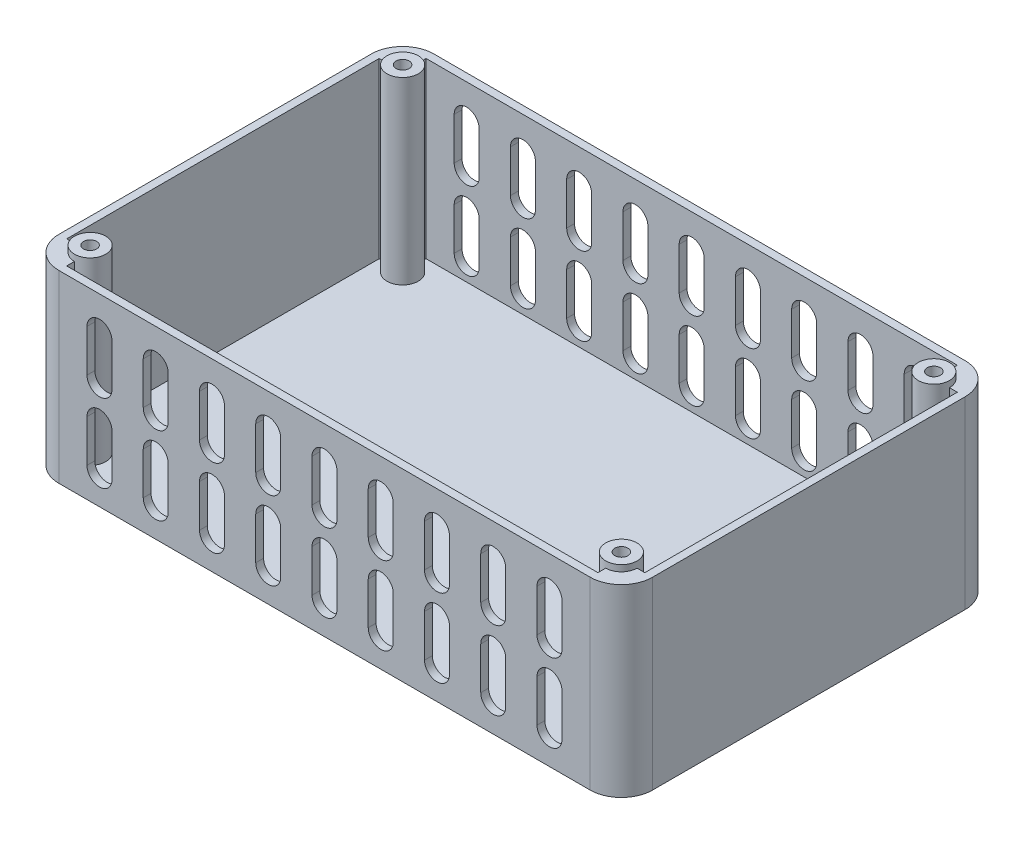
from build123d import *

# Parameters (mm, degrees)
SKETCH25_W                  = 190
SKETCH25_H                  = 120
BOSS_EXTRUDE5_DEPTH         = 55
FILLET2_R                   = 10
SHELL4_T                    = -2.5
SKETCH26_R                  = 5
BOSS_EXTRUDE8_DEPTH         = 57.5
TAP_DRILL_FOR_M5_TAP1_D     = 4.2
TAP_DRILL_FOR_M5_TAP1_DEPTH = 20
TAP_DRILL_FOR_M5_TAP1_TIP   = 1.2618073
BOSS_EXTRUDE10_DEPTH        = 1
CUT_EXTRUDE2_DEPTH          = 3
BOSS_EXTRUDE13_DEPTH        = 3
BOSS_EXTRUDE14_DEPTH        = 55.5
CUT_EXTRUDE3_DEPTH          = 3


with BuildPart() as part:
    # Sketch25 → Boss-Extrude5 (new body)
    with BuildSketch(Plane(origin=(0, 0, 0), x_dir=(1, 0, 0), z_dir=(0, 1, 0))):
        with Locations((-0.175936119, -144.891398577)):
            Rectangle(SKETCH25_W, SKETCH25_H)
    extrude(amount=BOSS_EXTRUDE5_DEPTH)

    # Fillet2
    fillet2_edges = [part.edges().sort_by_distance(p)[0] for p in [
        (-95.175936119, 27.5, 84.891398577),
        (94.824063881, 27.5, 84.891398577),
        (94.824063881, 27.5, 204.891398577),
        (-95.175936119, 27.5, 204.891398577),
    ]]
    fillet(fillet2_edges, radius=FILLET2_R)

    # Shell4
    shell4_openings = [part.faces().sort_by_distance(p)[0] for p in [
        (-0.175936119, 55, 144.891398577),
    ]]
    offset(amount=SHELL4_T, openings=shell4_openings, kind=Kind.INTERSECTION)

    # Sketch26 → Boss-Extrude8 (add)
    with BuildSketch(Plane(origin=(0, 2.5, 0), x_dir=(1, 0, 0), z_dir=(0, 1, 0))):
        with Locations((-85.175936119, -94.891398577)):
            Circle(SKETCH26_R)
        with Locations((84.824063881, -94.891398577)):
            Circle(SKETCH26_R)
        with Locations((-85.175936119, -194.891398577)):
            Circle(SKETCH26_R)
        with Locations((84.824063881, -194.891398577)):
            Circle(SKETCH26_R)
    extrude(amount=BOSS_EXTRUDE8_DEPTH)

    # Tap Drill for M5 Tap1
    with Locations(Plane(origin=(0, 60, 0), x_dir=(1, 0, 0), z_dir=(0, 1, 0))):
        with Locations((-85.175936119, -94.891398577), (-85.175936119, -194.891398577), (84.824063881, -94.891398577), (84.824063881, -194.891398577)):
            Hole(TAP_DRILL_FOR_M5_TAP1_D / 2, depth=TAP_DRILL_FOR_M5_TAP1_DEPTH)
            with Locations((0, 0, -(TAP_DRILL_FOR_M5_TAP1_DEPTH + TAP_DRILL_FOR_M5_TAP1_TIP / 2))):  # 118° drill point
                Cone(0, TAP_DRILL_FOR_M5_TAP1_D / 2, TAP_DRILL_FOR_M5_TAP1_TIP, mode=Mode.SUBTRACT)

    # Sketch37 → Boss-Extrude10 (add)
    with BuildSketch(Plane.XZ):
        with BuildLine():
            Line((94.824063881, 94.891398577), (94.824063881, 194.891398577))
            ThreePointArc((94.824063881, 194.891398577), (91.895131693, 201.962466389), (84.824063881, 204.891398577))
            Line((84.824063881, 204.891398577), (-85.175936119, 204.891398577))
            ThreePointArc((-85.175936119, 204.891398577), (-92.247003931, 201.962466389), (-95.175936119, 194.891398577))
            Line((-95.175936119, 194.891398577), (-95.175936119, 94.891398577))
            ThreePointArc((-95.175936119, 94.891398577), (-92.247003931, 87.820330766), (-85.175936119, 84.891398577))
            Line((-85.175936119, 84.891398577), (84.824063881, 84.891398577))
            ThreePointArc((84.824063881, 84.891398577), (91.895131693, 87.820330766), (94.824063881, 94.891398577))
        make_face()
    extrude(amount=BOSS_EXTRUDE10_DEPTH)

    # Sketch41 → Cut-Extrude2 (cut)
    with BuildSketch(Plane(origin=(0, 0, 84.891398577), x_dir=(-1, 0, 0), z_dir=(0, 0, -1))):
        with BuildLine():
            Line((-67.824063881, 47), (-67.824063881, 33.5))
            ThreePointArc((-67.824063881, 33.5), (-71.824063881, 29.5), (-75.824063881, 33.5))
            Line((-75.824063881, 33.5), (-75.824063881, 47))
            ThreePointArc((-75.824063881, 47), (-71.824063881, 51), (-67.824063881, 47))
        make_face()
        with BuildLine():
            Line((-49.824063881, 47), (-49.824063881, 33.5))
            ThreePointArc((-49.824063881, 33.5), (-53.824063881, 29.5), (-57.824063881, 33.5))
            Line((-57.824063881, 33.5), (-57.824063881, 47))
            ThreePointArc((-57.824063881, 47), (-53.824063881, 51), (-49.824063881, 47))
        make_face()
        with BuildLine():
            Line((-31.824063881, 47), (-31.824063881, 33.5))
            ThreePointArc((-31.824063881, 33.5), (-35.824063881, 29.5), (-39.824063881, 33.5))
            Line((-39.824063881, 33.5), (-39.824063881, 47))
            ThreePointArc((-39.824063881, 47), (-35.824063881, 51), (-31.824063881, 47))
        make_face()
        with BuildLine():
            Line((-13.824063881, 47), (-13.824063881, 33.5))
            ThreePointArc((-13.824063881, 33.5), (-17.824063881, 29.5), (-21.824063881, 33.5))
            Line((-21.824063881, 33.5), (-21.824063881, 47))
            ThreePointArc((-21.824063881, 47), (-17.824063881, 51), (-13.824063881, 47))
        make_face()
        with BuildLine():
            Line((4.175936119, 47), (4.175936119, 33.5))
            ThreePointArc((4.175936119, 33.5), (0.175936119, 29.5), (-3.824063881, 33.5))
            Line((-3.824063881, 33.5), (-3.824063881, 47))
            ThreePointArc((-3.824063881, 47), (0.175936119, 51), (4.175936119, 47))
        make_face()
        with BuildLine():
            Line((22.175936119, 47), (22.175936119, 33.5))
            ThreePointArc((22.175936119, 33.5), (18.175936119, 29.5), (14.175936119, 33.5))
            Line((14.175936119, 33.5), (14.175936119, 47))
            ThreePointArc((14.175936119, 47), (18.175936119, 51), (22.175936119, 47))
        make_face()
        with BuildLine():
            Line((40.175936119, 47), (40.175936119, 33.5))
            ThreePointArc((40.175936119, 33.5), (36.175936119, 29.5), (32.175936119, 33.5))
            Line((32.175936119, 33.5), (32.175936119, 47))
            ThreePointArc((32.175936119, 47), (36.175936119, 51), (40.175936119, 47))
        make_face()
        with BuildLine():
            Line((58.175936119, 47), (58.175936119, 33.5))
            ThreePointArc((58.175936119, 33.5), (54.175936119, 29.5), (50.175936119, 33.5))
            Line((50.175936119, 33.5), (50.175936119, 47))
            ThreePointArc((50.175936119, 47), (54.175936119, 51), (58.175936119, 47))
        make_face()
        with BuildLine():
            Line((76.175936119, 47), (76.175936119, 33.5))
            ThreePointArc((76.175936119, 33.5), (72.175936119, 29.5), (68.175936119, 33.5))
            Line((68.175936119, 33.5), (68.175936119, 47))
            ThreePointArc((68.175936119, 47), (72.175936119, 51), (76.175936119, 47))
        make_face()
        with BuildLine():
            Line((-49.824063881, 22), (-49.824063881, 8.5))
            ThreePointArc((-49.824063881, 8.5), (-53.824063881, 4.5), (-57.824063881, 8.5))
            Line((-57.824063881, 8.5), (-57.824063881, 22))
            ThreePointArc((-57.824063881, 22), (-53.824063881, 26), (-49.824063881, 22))
        make_face()
        with BuildLine():
            Line((-31.824063881, 22), (-31.824063881, 8.5))
            ThreePointArc((-31.824063881, 8.5), (-35.824063881, 4.5), (-39.824063881, 8.5))
            Line((-39.824063881, 8.5), (-39.824063881, 22))
            ThreePointArc((-39.824063881, 22), (-35.824063881, 26), (-31.824063881, 22))
        make_face()
        with BuildLine():
            Line((-13.824063881, 22), (-13.824063881, 8.5))
            ThreePointArc((-13.824063881, 8.5), (-17.824063881, 4.5), (-21.824063881, 8.5))
            Line((-21.824063881, 8.5), (-21.824063881, 22))
            ThreePointArc((-21.824063881, 22), (-17.824063881, 26), (-13.824063881, 22))
        make_face()
        with BuildLine():
            Line((4.175936119, 22), (4.175936119, 8.5))
            ThreePointArc((4.175936119, 8.5), (0.175936119, 4.5), (-3.824063881, 8.5))
            Line((-3.824063881, 8.5), (-3.824063881, 22))
            ThreePointArc((-3.824063881, 22), (0.175936119, 26), (4.175936119, 22))
        make_face()
        with BuildLine():
            Line((22.175936119, 22), (22.175936119, 8.5))
            ThreePointArc((22.175936119, 8.5), (18.175936119, 4.5), (14.175936119, 8.5))
            Line((14.175936119, 8.5), (14.175936119, 22))
            ThreePointArc((14.175936119, 22), (18.175936119, 26), (22.175936119, 22))
        make_face()
        with BuildLine():
            Line((40.175936119, 22), (40.175936119, 8.5))
            ThreePointArc((40.175936119, 8.5), (36.175936119, 4.5), (32.175936119, 8.5))
            Line((32.175936119, 8.5), (32.175936119, 22))
            ThreePointArc((32.175936119, 22), (36.175936119, 26), (40.175936119, 22))
        make_face()
        with BuildLine():
            Line((58.175936119, 22), (58.175936119, 8.5))
            ThreePointArc((58.175936119, 8.5), (54.175936119, 4.5), (50.175936119, 8.5))
            Line((50.175936119, 8.5), (50.175936119, 22))
            ThreePointArc((50.175936119, 22), (54.175936119, 26), (58.175936119, 22))
        make_face()
        with BuildLine():
            Line((76.175936119, 22), (76.175936119, 8.5))
            ThreePointArc((76.175936119, 8.5), (72.175936119, 4.5), (68.175936119, 8.5))
            Line((68.175936119, 8.5), (68.175936119, 22))
            ThreePointArc((68.175936119, 22), (72.175936119, 26), (76.175936119, 22))
        make_face()
        with BuildLine():
            Line((-67.824063881, 22), (-67.824063881, 8.5))
            ThreePointArc((-67.824063881, 8.5), (-71.824063881, 4.5), (-75.824063881, 8.5))
            Line((-75.824063881, 8.5), (-75.824063881, 22))
            ThreePointArc((-75.824063881, 22), (-71.824063881, 26), (-67.824063881, 22))
        make_face()
    extrude(amount=-CUT_EXTRUDE2_DEPTH, mode=Mode.SUBTRACT)

    # Sketch45 → Boss-Extrude13 (add)
    with BuildSketch(Plane(origin=(0, 55, 0), x_dir=(1, 0, 0), z_dir=(0, 1, 0))):
        with BuildLine():
            Line((94.824063881, -94.891398577), (94.824063881, -194.891398577))
            ThreePointArc((94.824063881, -194.891398577), (91.895131693, -201.962466389), (84.824063881, -204.891398577))
            Line((84.824063881, -204.891398577), (-85.175936119, -204.891398577))
            ThreePointArc((-85.175936119, -204.891398577), (-92.247003931, -201.962466389), (-95.175936119, -194.891398577))
            Line((-95.175936119, -194.891398577), (-95.175936119, -94.891398577))
            ThreePointArc((-95.175936119, -94.891398577), (-92.247003931, -87.820330766), (-85.175936119, -84.891398577))
            Line((-85.175936119, -84.891398577), (84.824063881, -84.891398577))
            ThreePointArc((84.824063881, -84.891398577), (91.895131693, -87.820330766), (94.824063881, -94.891398577))
        make_face()
        with BuildLine():
            Line((-85.175936119, -202.391398577), (84.824063881, -202.391398577))
            ThreePointArc((84.824063881, -202.391398577), (90.12736474, -200.194699436), (92.324063881, -194.891398577))
            Line((92.324063881, -194.891398577), (92.324063881, -94.891398577))
            ThreePointArc((92.324063881, -94.891398577), (90.12736474, -89.588097719), (84.824063881, -87.391398577))
            Line((84.824063881, -87.391398577), (-85.175936119, -87.391398577))
            ThreePointArc((-85.175936119, -87.391398577), (-90.479236978, -89.588097719), (-92.675936119, -94.891398577))
            Line((-92.675936119, -94.891398577), (-92.675936119, -194.891398577))
            ThreePointArc((-92.675936119, -194.891398577), (-90.479236978, -200.194699436), (-85.175936119, -202.391398577))
        make_face(mode=Mode.SUBTRACT)
    extrude(amount=BOSS_EXTRUDE13_DEPTH)

    # Sketch44 → Boss-Extrude14 (add)
    with BuildSketch(Plane(origin=(0, 2.5, 0), x_dir=(1, 0, 0), z_dir=(0, 1, 0))):
        with BuildLine():
            Line((-92.675936119, -94.891398577), (-90.175936119, -94.891398577))
            ThreePointArc((-90.175936119, -94.891398577), (-88.711470025, -91.355864672), (-85.175936119, -89.891398577))
            Line((-85.175936119, -89.891398577), (-85.175936119, -87.391398577))
            ThreePointArc((-85.175936119, -87.391398577), (-90.479236978, -89.588097719), (-92.675936119, -94.891398577))
        make_face()
        with BuildLine():
            Line((92.324063881, -94.891398577), (89.824063881, -94.891398577))
            ThreePointArc((89.824063881, -94.891398577), (88.359597787, -91.355864672), (84.824063881, -89.891398577))
            Line((84.824063881, -89.891398577), (84.824063881, -87.391398577))
            ThreePointArc((84.824063881, -87.391398577), (90.12736474, -89.588097719), (92.324063881, -94.891398577))
        make_face()
        with BuildLine():
            Line((84.824063881, -202.391398577), (84.824063881, -199.891398577))
            ThreePointArc((84.824063881, -199.891398577), (88.359597787, -198.426932483), (89.824063881, -194.891398577))
            Line((89.824063881, -194.891398577), (92.324063881, -194.891398577))
            ThreePointArc((92.324063881, -194.891398577), (90.12736474, -200.194699436), (84.824063881, -202.391398577))
        make_face()
        with BuildLine():
            Line((-92.675936119, -194.891398577), (-90.175936119, -194.891398577))
            ThreePointArc((-90.175936119, -194.891398577), (-88.711470025, -198.426932483), (-85.175936119, -199.891398577))
            Line((-85.175936119, -199.891398577), (-85.175936119, -202.391398577))
            ThreePointArc((-85.175936119, -202.391398577), (-90.479236978, -200.194699436), (-92.675936119, -194.891398577))
        make_face()
    extrude(amount=BOSS_EXTRUDE14_DEPTH)

    # Sketch48 → Cut-Extrude3 (cut)
    with BuildSketch(Plane.XY.offset(204.891398577)):
        with BuildLine():
            Line((-50.175936119, 33.5), (-50.175936119, 47))
            ThreePointArc((-50.175936119, 47), (-54.175936119, 51), (-58.175936119, 47))
            Line((-58.175936119, 47), (-58.175936119, 33.5))
            ThreePointArc((-58.175936119, 33.5), (-54.175936119, 29.5), (-50.175936119, 33.5))
        make_face()
        with BuildLine():
            Line((-68.175936119, 33.5), (-68.175936119, 47))
            ThreePointArc((-68.175936119, 47), (-72.175936119, 51), (-76.175936119, 47))
            Line((-76.175936119, 47), (-76.175936119, 33.5))
            ThreePointArc((-76.175936119, 33.5), (-72.175936119, 29.5), (-68.175936119, 33.5))
        make_face()
        with BuildLine():
            Line((-32.175936119, 33.5), (-32.175936119, 47))
            ThreePointArc((-32.175936119, 47), (-36.175936119, 51), (-40.175936119, 47))
            Line((-40.175936119, 47), (-40.175936119, 33.5))
            ThreePointArc((-40.175936119, 33.5), (-36.175936119, 29.5), (-32.175936119, 33.5))
        make_face()
        with BuildLine():
            Line((-14.175936119, 33.5), (-14.175936119, 47))
            ThreePointArc((-14.175936119, 47), (-18.175936119, 51), (-22.175936119, 47))
            Line((-22.175936119, 47), (-22.175936119, 33.5))
            ThreePointArc((-22.175936119, 33.5), (-18.175936119, 29.5), (-14.175936119, 33.5))
        make_face()
        with BuildLine():
            Line((3.824063881, 33.5), (3.824063881, 47))
            ThreePointArc((3.824063881, 47), (-0.175936119, 51), (-4.175936119, 47))
            Line((-4.175936119, 47), (-4.175936119, 33.5))
            ThreePointArc((-4.175936119, 33.5), (-0.175936119, 29.5), (3.824063881, 33.5))
        make_face()
        with BuildLine():
            Line((21.824063881, 33.5), (21.824063881, 47))
            ThreePointArc((21.824063881, 47), (17.824063881, 51), (13.824063881, 47))
            Line((13.824063881, 47), (13.824063881, 33.5))
            ThreePointArc((13.824063881, 33.5), (17.824063881, 29.5), (21.824063881, 33.5))
        make_face()
        with BuildLine():
            Line((39.824063881, 33.5), (39.824063881, 47))
            ThreePointArc((39.824063881, 47), (35.824063881, 51), (31.824063881, 47))
            Line((31.824063881, 47), (31.824063881, 33.5))
            ThreePointArc((31.824063881, 33.5), (35.824063881, 29.5), (39.824063881, 33.5))
        make_face()
        with BuildLine():
            Line((57.824063881, 33.5), (57.824063881, 47))
            ThreePointArc((57.824063881, 47), (53.824063881, 51), (49.824063881, 47))
            Line((49.824063881, 47), (49.824063881, 33.5))
            ThreePointArc((49.824063881, 33.5), (53.824063881, 29.5), (57.824063881, 33.5))
        make_face()
        with BuildLine():
            Line((75.824063881, 33.5), (75.824063881, 47))
            ThreePointArc((75.824063881, 47), (71.824063881, 51), (67.824063881, 47))
            Line((67.824063881, 47), (67.824063881, 33.5))
            ThreePointArc((67.824063881, 33.5), (71.824063881, 29.5), (75.824063881, 33.5))
        make_face()
        with BuildLine():
            Line((-50.175936119, 8.5), (-50.175936119, 22))
            ThreePointArc((-50.175936119, 22), (-54.175936119, 26), (-58.175936119, 22))
            Line((-58.175936119, 22), (-58.175936119, 8.5))
            ThreePointArc((-58.175936119, 8.5), (-54.175936119, 4.5), (-50.175936119, 8.5))
        make_face()
        with BuildLine():
            Line((-32.175936119, 8.5), (-32.175936119, 22))
            ThreePointArc((-32.175936119, 22), (-36.175936119, 26), (-40.175936119, 22))
            Line((-40.175936119, 22), (-40.175936119, 8.5))
            ThreePointArc((-40.175936119, 8.5), (-36.175936119, 4.5), (-32.175936119, 8.5))
        make_face()
        with BuildLine():
            Line((-14.175936119, 8.5), (-14.175936119, 22))
            ThreePointArc((-14.175936119, 22), (-18.175936119, 26), (-22.175936119, 22))
            Line((-22.175936119, 22), (-22.175936119, 8.5))
            ThreePointArc((-22.175936119, 8.5), (-18.175936119, 4.5), (-14.175936119, 8.5))
        make_face()
        with BuildLine():
            Line((3.824063881, 8.5), (3.824063881, 22))
            ThreePointArc((3.824063881, 22), (-0.175936119, 26), (-4.175936119, 22))
            Line((-4.175936119, 22), (-4.175936119, 8.5))
            ThreePointArc((-4.175936119, 8.5), (-0.175936119, 4.5), (3.824063881, 8.5))
        make_face()
        with BuildLine():
            Line((21.824063881, 8.5), (21.824063881, 22))
            ThreePointArc((21.824063881, 22), (17.824063881, 26), (13.824063881, 22))
            Line((13.824063881, 22), (13.824063881, 8.5))
            ThreePointArc((13.824063881, 8.5), (17.824063881, 4.5), (21.824063881, 8.5))
        make_face()
        with BuildLine():
            Line((39.824063881, 8.5), (39.824063881, 22))
            ThreePointArc((39.824063881, 22), (35.824063881, 26), (31.824063881, 22))
            Line((31.824063881, 22), (31.824063881, 8.5))
            ThreePointArc((31.824063881, 8.5), (35.824063881, 4.5), (39.824063881, 8.5))
        make_face()
        with BuildLine():
            Line((57.824063881, 8.5), (57.824063881, 22))
            ThreePointArc((57.824063881, 22), (53.824063881, 26), (49.824063881, 22))
            Line((49.824063881, 22), (49.824063881, 8.5))
            ThreePointArc((49.824063881, 8.5), (53.824063881, 4.5), (57.824063881, 8.5))
        make_face()
        with BuildLine():
            Line((75.824063881, 8.5), (75.824063881, 22))
            ThreePointArc((75.824063881, 22), (71.824063881, 26), (67.824063881, 22))
            Line((67.824063881, 22), (67.824063881, 8.5))
            ThreePointArc((67.824063881, 8.5), (71.824063881, 4.5), (75.824063881, 8.5))
        make_face()
        with BuildLine():
            Line((-68.175936119, 8.5), (-68.175936119, 22))
            ThreePointArc((-68.175936119, 22), (-72.175936119, 26), (-76.175936119, 22))
            Line((-76.175936119, 22), (-76.175936119, 8.5))
            ThreePointArc((-76.175936119, 8.5), (-72.175936119, 4.5), (-68.175936119, 8.5))
        make_face()
    extrude(amount=-CUT_EXTRUDE3_DEPTH, mode=Mode.SUBTRACT)


solid = part.part
